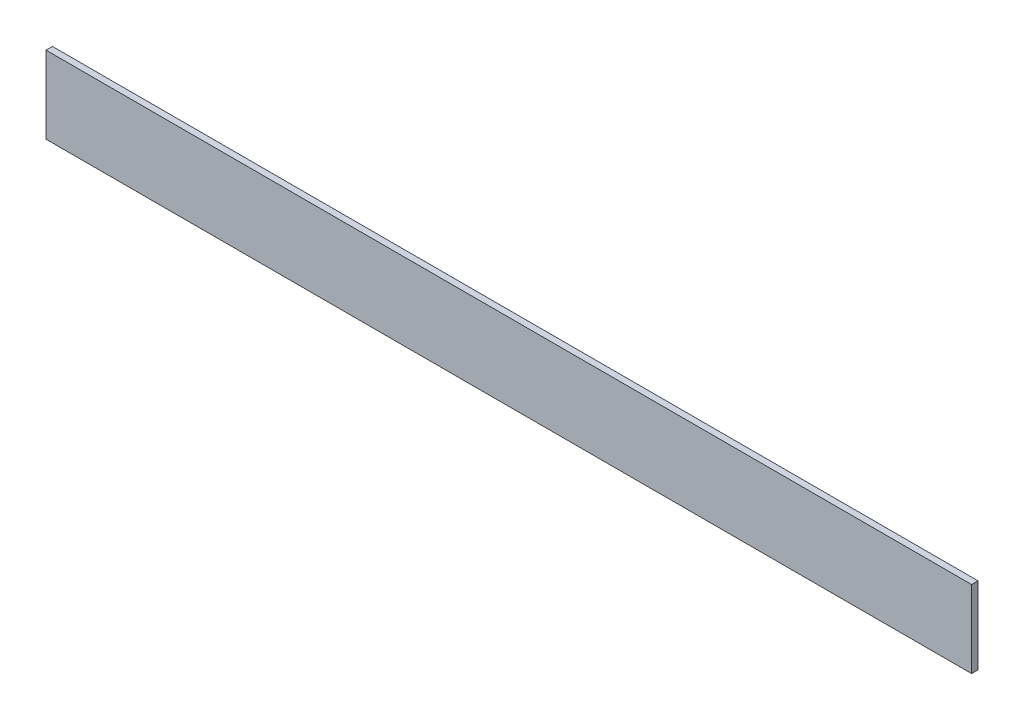
from build123d import *

# Parameters (mm, degrees)
SKETCH1_W           = 6.35
SKETCH1_H           = 76.2
BOSS_EXTRUDE1_DEPTH = 914.4


with BuildPart() as part:
    # Sketch1 → Boss-Extrude1 (new body)
    with BuildSketch(Plane(origin=(0, 0, 0), x_dir=(0, 0, -1), z_dir=(1, 0, 0))):
        Rectangle(SKETCH1_W, SKETCH1_H)
    extrude(amount=BOSS_EXTRUDE1_DEPTH)


solid = part.part
